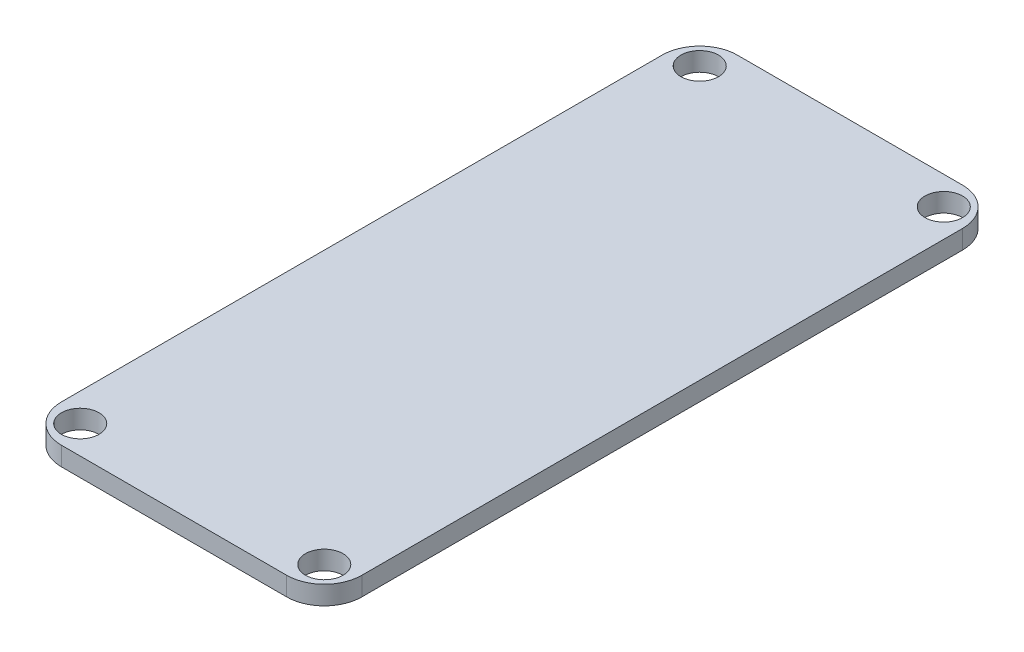
from build123d import *

# Parameters (mm, degrees)
SKETCH1_W           = 25.4
SKETCH1_H           = 57.15
BOSS_EXTRUDE1_DEPTH = 1.5875
SKETCH2_R           = 1.5875
CUT_EXTRUDE2_DEPTH  = 2.5875
FILLET1_R           = 3.175


with BuildPart() as part:
    # Sketch1 → Boss-Extrude1 (new body)
    with BuildSketch(Plane(origin=(0, 0, 0), x_dir=(1, 0, 0), z_dir=(0, 1, 0))):
        with Locations((12.7, 28.575)):
            Rectangle(SKETCH1_W, SKETCH1_H)
    extrude(amount=BOSS_EXTRUDE1_DEPTH)

    # Sketch2 → Cut-Extrude2 (cut, through all)
    with BuildSketch(Plane(origin=(0, 1.5875, 0), x_dir=(1, 0, 0), z_dir=(0, 1, 0))):
        with Locations((2.38125, 54.76875)):
            Circle(SKETCH2_R)
        with Locations((23.01875, 54.76875)):
            Circle(SKETCH2_R)
        with Locations((23.01875, 2.38125)):
            Circle(SKETCH2_R)
        with Locations((2.38125, 2.38125)):
            Circle(SKETCH2_R)
    extrude(amount=-CUT_EXTRUDE2_DEPTH, mode=Mode.SUBTRACT)

    # Fillet1
    fillet1_edges = [part.edges().sort_by_distance(p)[0] for p in [
        (0, 0.79375, -57.15),
        (25.4, 0.79375, -57.15),
        (25.4, 0.79375, 0),
        (0, 0.79375, 0),
    ]]
    fillet(fillet1_edges, radius=FILLET1_R)


solid = part.part
